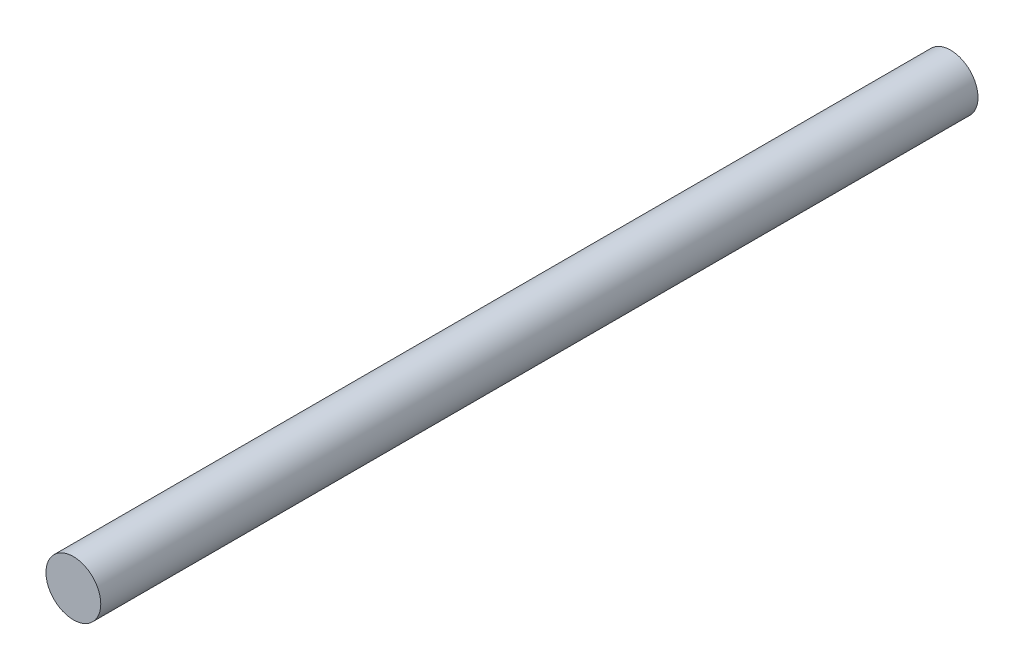
from build123d import *

# Parameters (mm, degrees)
SKETCH1_R           = 3.175
BOSS_EXTRUDE1_DEPTH = 50.8


with BuildPart() as part:
    # Sketch1 → Boss-Extrude1 (new body, symmetric)
    with BuildSketch(Plane.XY):
        Circle(SKETCH1_R)
    extrude(amount=BOSS_EXTRUDE1_DEPTH, both=True)


solid = part.part
